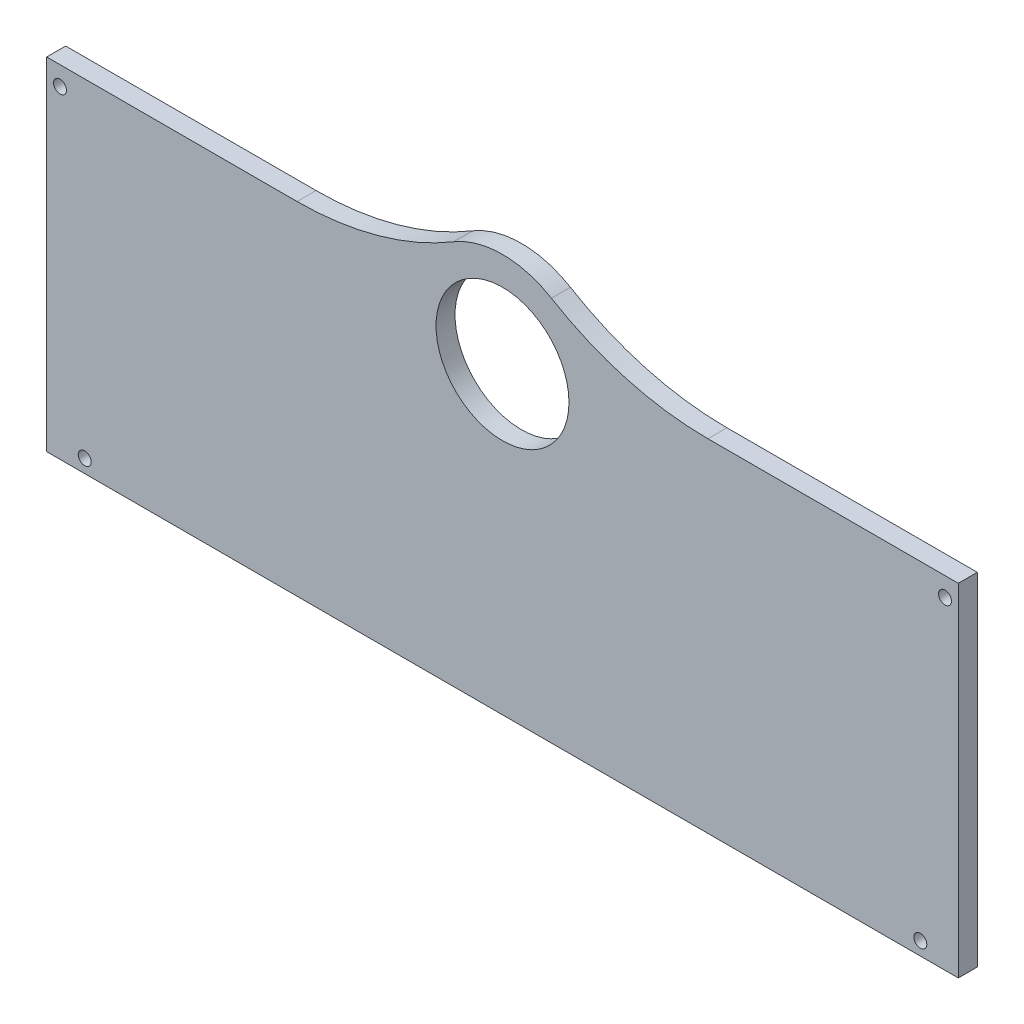
from build123d import *

# Parameters (mm, degrees)
SKETCH1_R           = 22.225
BOSS_EXTRUDE1_DEPTH = 6.35
SKETCH2_R           = 2.159
CUT_EXTRUDE1_DEPTH  = 7.35


with BuildPart() as part:
    # Sketch1 → Boss-Extrude1 (new body)
    with BuildSketch(Plane.XY):
        with BuildLine():
            Line((-152.4, 12.7), (-68.685751798, 12.7))
            ThreePointArc((-68.685751798, 12.7), (-41.532009619, 16.395790255), (-16.353750428, 27.214285714))
            ThreePointArc((-16.353750428, 27.214285714), (0, 31.75), (16.353750428, 27.214285714))
            ThreePointArc((16.353750428, 27.214285714), (41.532009619, 16.395790255), (68.685751798, 12.7))
            Line((68.685751798, 12.7), (152.4, 12.7))
            Line((152.4, 12.7), (152.4, -101.6))
            Line((152.4, -101.6), (-152.4, -101.6))
            Line((-152.4, -101.6), (-152.4, 12.7))
        make_face()
        Circle(SKETCH1_R, mode=Mode.SUBTRACT)
    extrude(amount=BOSS_EXTRUDE1_DEPTH)

    # Sketch2 → Cut-Extrude1 (cut, through all)
    with BuildSketch(Plane.XY.offset(6.35)):
        with Locations((-139.7, -97.155)):
            Circle(SKETCH2_R)
        with Locations((-147.955, 6.35)):
            Circle(SKETCH2_R)
        with Locations((147.955, 6.35)):
            Circle(SKETCH2_R)
        with Locations((139.7, -97.155)):
            Circle(SKETCH2_R)
    extrude(amount=-CUT_EXTRUDE1_DEPTH, mode=Mode.SUBTRACT)


solid = part.part
